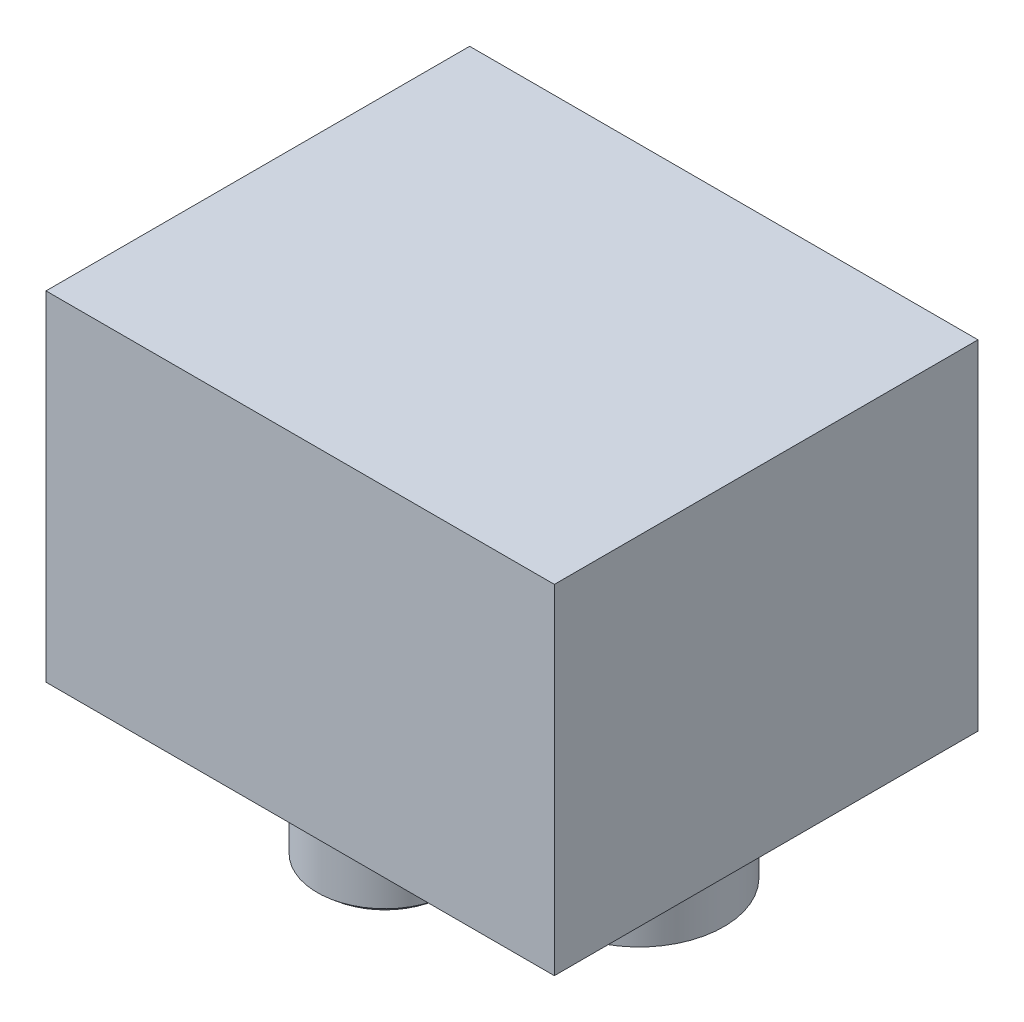
from build123d import *

# Parameters (mm, degrees)
SKETCH1_W           = 76.2
SKETCH1_H           = 50.8
BOSS_EXTRUDE1_DEPTH = 31.75
SKETCH4_W           = 12.7
SKETCH4_H           = 12.7


with BuildPart() as part:
    # Sketch1 → Boss-Extrude1 (new body, symmetric)
    with BuildSketch(Plane.XY):
        with Locations((38.1, 25.4)):
            Rectangle(SKETCH1_W, SKETCH1_H)
    extrude(amount=BOSS_EXTRUDE1_DEPTH, both=True)

    # Sketch3 → Revolve1 (revolve)
    with BuildSketch(Plane.XY):
        with BuildLine():
            Line((12.7, 0), (12.7, -12.7))
            Line((12.7, -12.7), (8.89, -12.7))
            Line((8.89, -12.7), (8.89, -28.575))
            ThreePointArc((8.89, -28.575), (13.599228719, -31.3489681), (19.05, -31.75))
            Line((19.05, -31.75), (19.05, -28.575))
            Line((19.05, -28.575), (19.05, 0))
            Line((19.05, 0), (12.7, 0))
        make_face()
    revolve(axis=Axis((19.05, -28.575, 0), (0, 1, 0)))

    # Sketch4 → Revolve2 (revolve)
    with BuildSketch(Plane.XY):
        with Locations((50.8, -6.35)):
            Rectangle(SKETCH4_W, SKETCH4_H)
    revolve(axis=Axis((57.15, 0, 0), (0, -1, 0)))


solid = part.part
